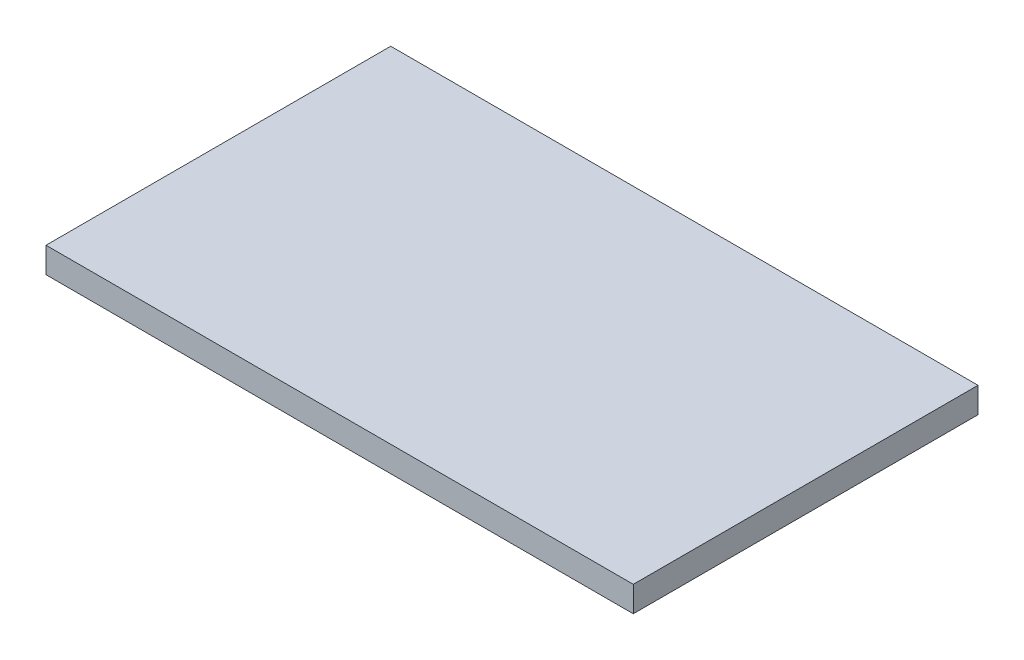
from build123d import *

# Parameters (mm, degrees)
SKETCH1_W           = 73.025
SKETCH1_H           = 42.8625
BOSS_EXTRUDE1_DEPTH = 3.175


with BuildPart() as part:
    # Sketch1 → Boss-Extrude1 (new body)
    with BuildSketch(Plane(origin=(0, 0, 0), x_dir=(1, 0, 0), z_dir=(0, 1, 0))):
        Rectangle(SKETCH1_W, SKETCH1_H)
    extrude(amount=BOSS_EXTRUDE1_DEPTH)


solid = part.part
